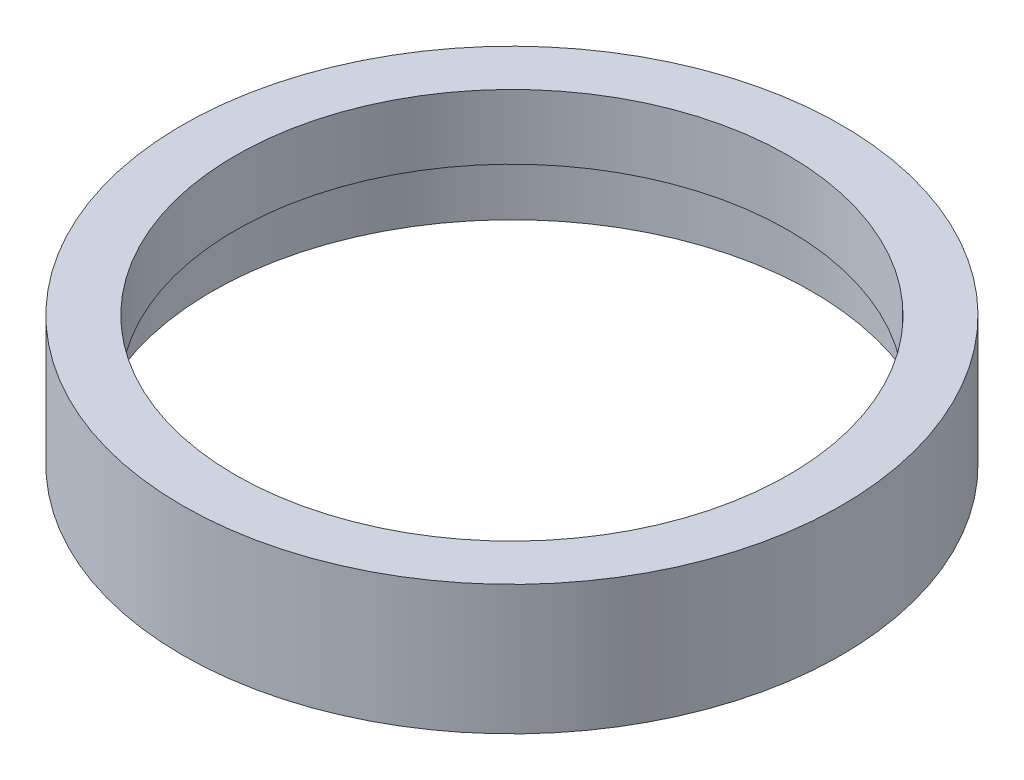
from build123d import *


with BuildPart() as part:
    # 草图1 → 旋转1 (revolve)
    with BuildSketch(Plane.XY, mode=Mode.PRIVATE) as revolve_1_sk:
        Polygon((25.5, 0), (25.5, 4.5), (26.1, 4.5), (26.1, 5.5), (23.5, 5.5), (23.5, 11), (28, 11), (28, 0), align=None)
    revolve(revolve_1_sk.sketch.rotate(Axis((0, 60.020820414, 0), (0, -1, 0)), 90), axis=Axis((0, 60.020820414, 0), (0, -1, 0)))  # turned: the seam where the file's is


solid = part.part
